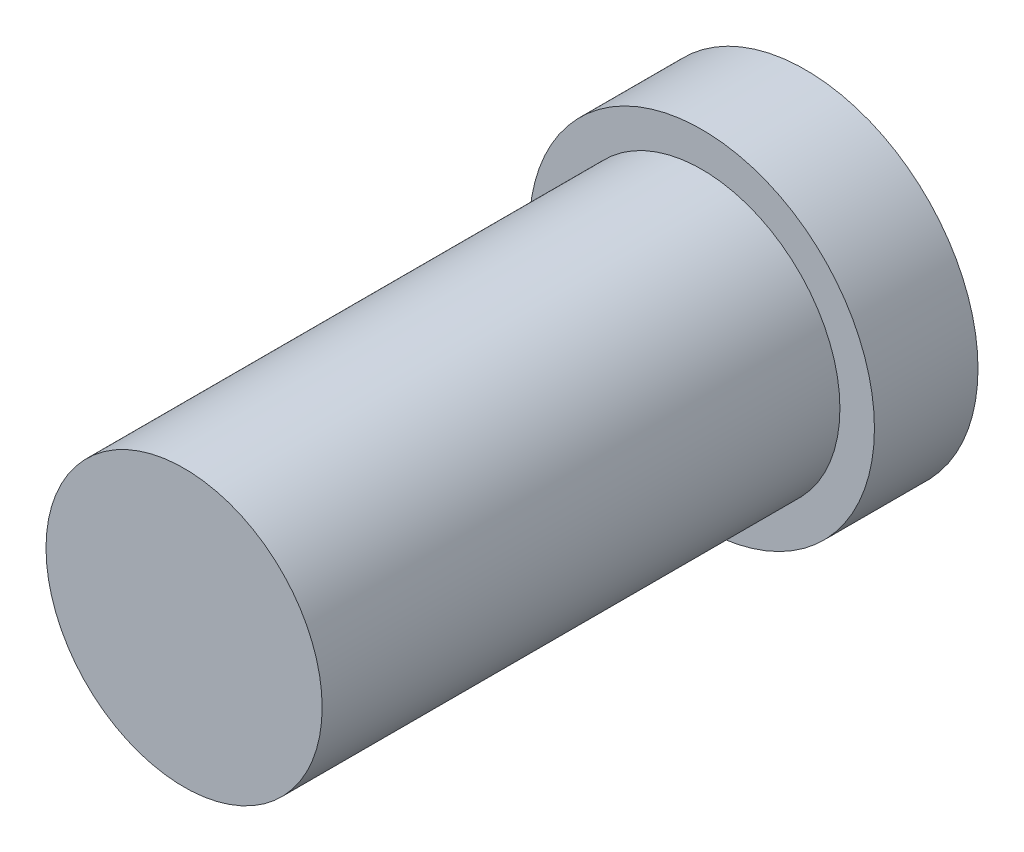
from build123d import *

# Parameters (mm, degrees)
SKETCH1_R           = 5
BOSS_EXTRUDE1_DEPTH = 3
SKETCH2_R           = 4
BOSS_EXTRUDE2_DEPTH = 15


with BuildPart() as part:
    # Sketch1 → Boss-Extrude1 (new body)
    with BuildSketch(Plane.XY):
        Circle(SKETCH1_R)
    extrude(amount=BOSS_EXTRUDE1_DEPTH)

    # Sketch2 → Boss-Extrude2 (add)
    with BuildSketch(Plane.XY.offset(3)):
        Circle(SKETCH2_R)
    extrude(amount=BOSS_EXTRUDE2_DEPTH)


solid = part.part
